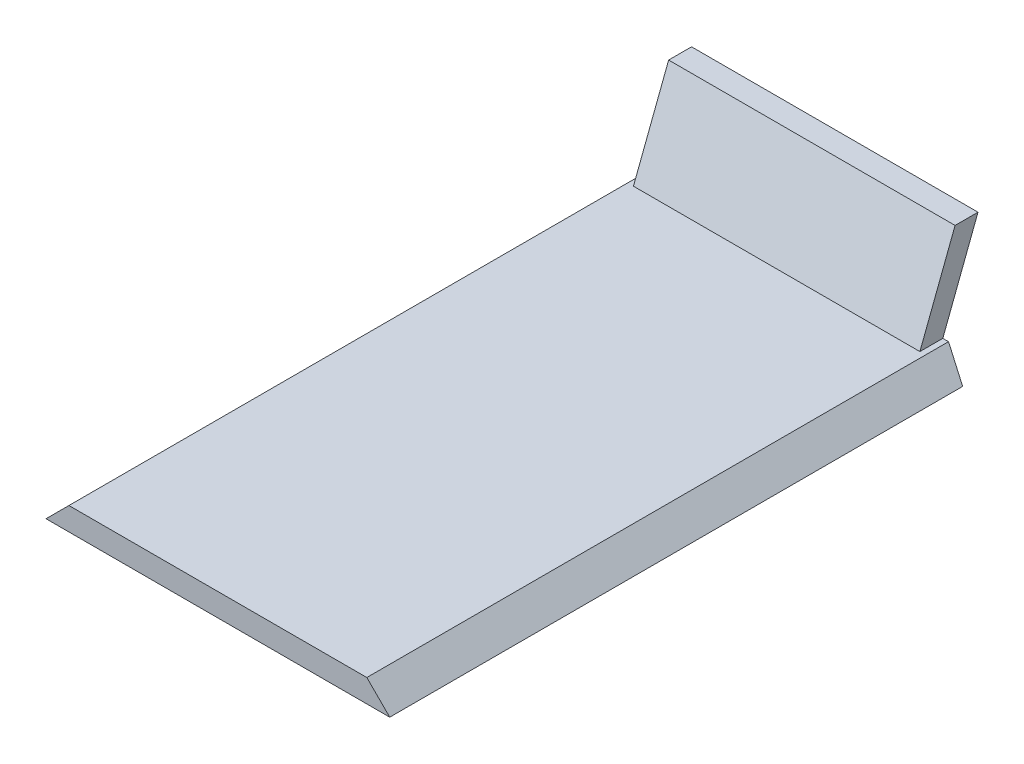
from build123d import *

# Parameters (mm, degrees)
BOSS_EXTRUDE1_DEPTH      = 127
BOSS_EXTRUDE1_DEPTH_BACK = 19.547940452
BOSS_EXTRUDE3_DEPTH      = 31.75


with BuildPart() as part:
    # Sketch1 → Boss-Extrude1 (new, two sides)
    with BuildSketch(Plane.XY) as boss_extrude1_sk:
        Polygon((-38.1, 0), (38.1, 0), (33.02, 5.08), (-33.02, 5.08), align=None)
    extrude(amount=BOSS_EXTRUDE1_DEPTH)
    extrude(boss_extrude1_sk.sketch, amount=-BOSS_EXTRUDE1_DEPTH_BACK)

    # Sketch3 → Boss-Extrude3 (add, symmetric)
    with BuildSketch(Plane(origin=(0, 0, 0), x_dir=(0, 0, -1), z_dir=(1, 0, 0))):
        Polygon((0, 0), (9.75014649, 25.4), (4.67014649, 25.4), (-5.08, 0), align=None)
    extrude(amount=BOSS_EXTRUDE3_DEPTH, both=True)

    # SurfaceCut2
    split(bisect_by=Plane(origin=(0, 0, 0), x_dir=(-1, 0, 0), z_dir=(0, -0.3583679495453043, -0.9335804264972002)), keep=Keep.BOTTOM)


solid = part.part
